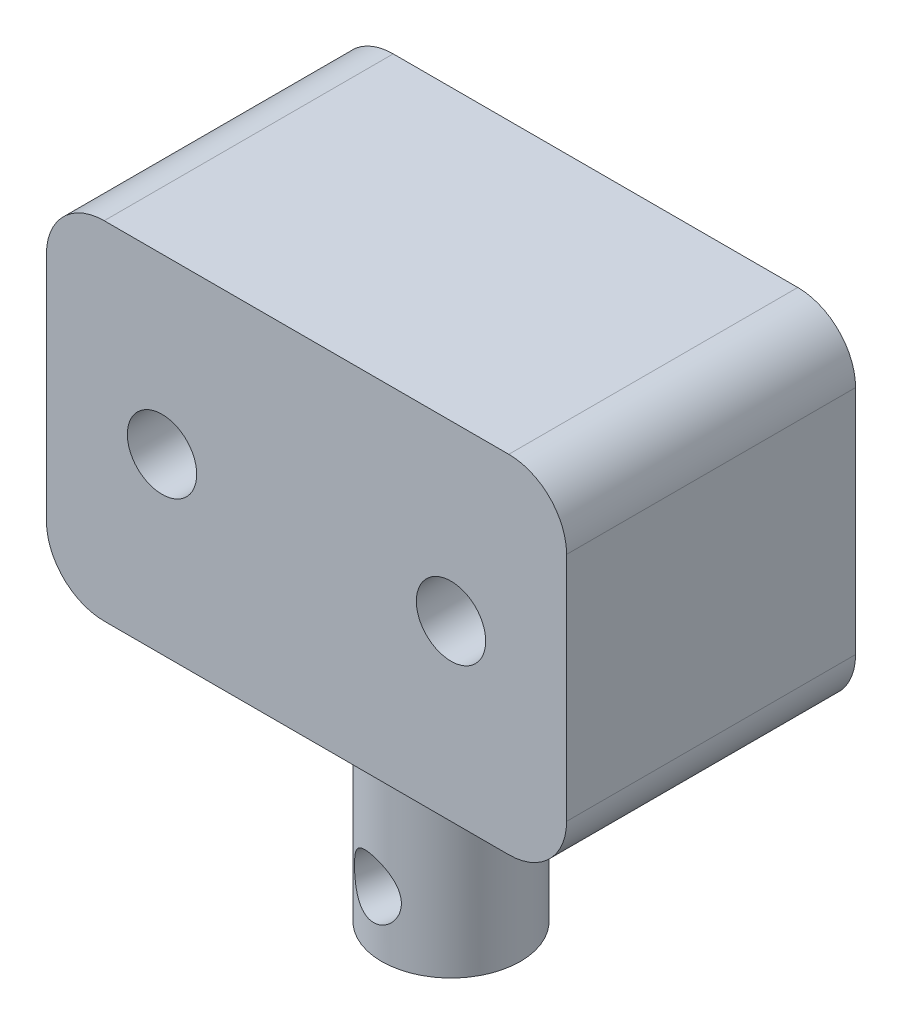
from build123d import *

# Parameters (mm, degrees)
SKETCH_1_W               = 45
SKETCH_1_H               = 30
SKETCH_1_R               = 3
EXTRUDE_1_DEPTH          = 25
FILLET_1_R               = 5
SKETCH_2_R               = 6
EXTRUDE_2_DEPTH          = 20
CUT_EXTRUDE_1_DEPTH      = 45.697065981
CUT_EXTRUDE_1_DEPTH_BACK = 45.697065981
SKETCH_3_R               = 2.5


with BuildPart() as part:
    # 草图1 → 凸台-拉伸1 (new body)
    with BuildSketch(Plane.XY):
        Rectangle(SKETCH_1_W, SKETCH_1_H)
        with Locations((-12.5, 0)):
            Circle(SKETCH_1_R, mode=Mode.SUBTRACT)
        with Locations((12.5, 0)):
            Circle(SKETCH_1_R, mode=Mode.SUBTRACT)
    extrude(amount=EXTRUDE_1_DEPTH)

    # 圆角1
    fillet_1_edges = [part.edges().sort_by_distance(p)[0] for p in [
        (22.5, 15, 12.5),
        (22.5, -15, 12.5),
        (-22.5, -15, 12.5),
        (-22.5, 15, 12.5),
    ]]
    fillet(fillet_1_edges, radius=FILLET_1_R)

    # 草图2 → 凸台-拉伸2 (add)
    with BuildSketch(Plane.XZ.offset(15)):
        with Locations((0, 12.5)):
            Circle(SKETCH_2_R)
    extrude(amount=EXTRUDE_2_DEPTH)

    # 草图3 → 切除-拉伸1 (cut, two sides: drawn at the far end of the back side and taken through both)
    with BuildSketch(Plane(origin=(-2.137625896, 0, 12.12307888), x_dir=(-0.9848077530122086, 0, -0.17364817766692736), z_dir=(0.17364817766692736, 0, -0.9848077530122086)).offset(-CUT_EXTRUDE_1_DEPTH_BACK)):
        with Locations((-2.170602221, -30)):
            Circle(SKETCH_3_R)
    extrude(amount=CUT_EXTRUDE_1_DEPTH + CUT_EXTRUDE_1_DEPTH_BACK, mode=Mode.SUBTRACT)


solid = part.part
